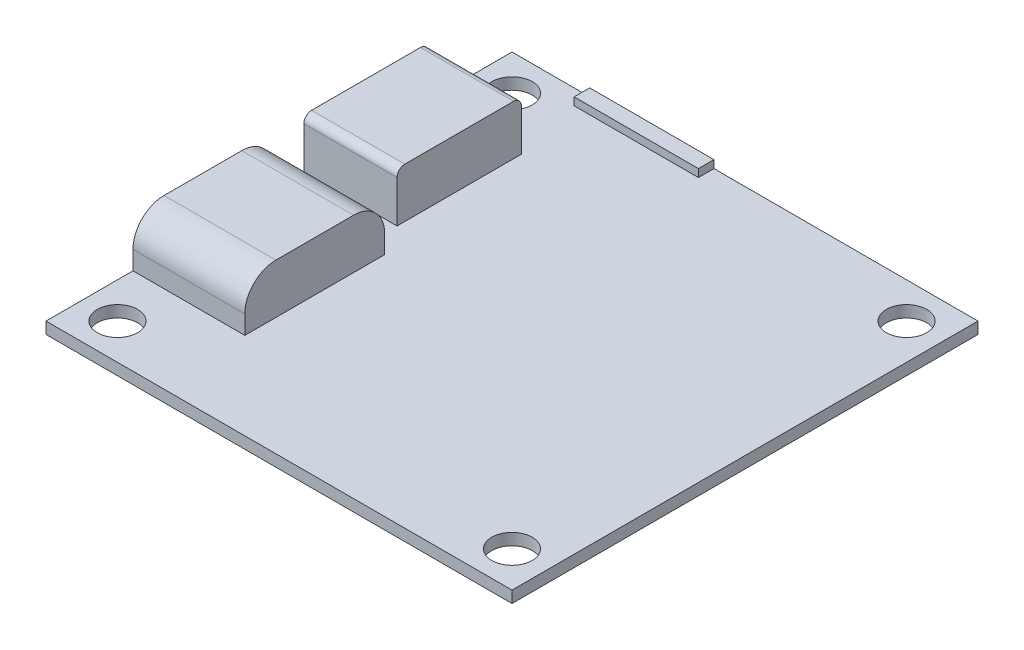
from build123d import *

# Parameters (mm, degrees)
SKETCH1_W               = 30
SKETCH1_H               = 30
BOSS_EXTRUDE1_DEPTH     = 0.375
SKETCH2_R               = 1.3
CUT_EXTRUDE1_DEPTH      = 1.75
MIRROR2_COPY_1_SKETCH_R = 1.3
MIRROR2_COPY_1_DEPTH    = 1.75
SKETCH3_W               = 7.2
SKETCH3_H               = 9
SKETCH3_W_2             = 6
SKETCH3_H_2             = 8
BOSS_EXTRUDE2_DEPTH     = 3.2
FILLET1_R               = 2
FILLET2_R               = 0.5
SKETCH4_W               = 8
SKETCH4_H               = 1
BOSS_EXTRUDE3_DEPTH     = 0.5


with BuildPart() as part:
    # Sketch1 → Boss-Extrude1 (new body, symmetric)
    with BuildSketch(Plane(origin=(0, 0, 0), x_dir=(1, 0, 0), z_dir=(0, 1, 0))):
        Rectangle(SKETCH1_W, SKETCH1_H)
    extrude(amount=BOSS_EXTRUDE1_DEPTH, both=True)

    # Sketch2 → Cut-Extrude1 (cut, through all)
    with BuildSketch(Plane(origin=(0, 0.375, 0), x_dir=(1, 0, 0), z_dir=(0, 1, 0))):
        with Locations((-12.7, 12.7)):
            Circle(SKETCH2_R)
    cut_extrude1 = extrude(amount=-CUT_EXTRUDE1_DEPTH, mode=Mode.SUBTRACT)

    # Mirror1: Cut-Extrude1 across plane
    add(cut_extrude1.mirror(Plane(origin=(0, 0, 0), x_dir=(0, 0, 1), z_dir=(1, 0, 0))), mode=Mode.SUBTRACT)

    # Mirror2: Cut-Extrude1 across plane
    add(cut_extrude1.mirror(Plane.XY), mode=Mode.SUBTRACT)

    # Mirror2 copy 1 sketch → Mirror2 copy 1 (cut, through all)
    with BuildSketch(Plane(origin=(0, 0.375, 0), x_dir=(-1, 0, 0), z_dir=(0, 1, 0))):
        with Locations((-12.7, 12.7)):
            Circle(MIRROR2_COPY_1_SKETCH_R)
    extrude(amount=-MIRROR2_COPY_1_DEPTH, mode=Mode.SUBTRACT)

    # Sketch3 → Boss-Extrude2 (add)
    with BuildSketch(Plane(origin=(0, 0.375, 0), x_dir=(1, 0, 0), z_dir=(0, 1, 0))):
        with Locations((-11.4, -4.9)):
            Rectangle(SKETCH3_W, SKETCH3_H)
        with Locations((-12, 5.6)):
            Rectangle(SKETCH3_W_2, SKETCH3_H_2)
    extrude(amount=BOSS_EXTRUDE2_DEPTH)

    # Fillet1
    fillet1_edges = [part.edges().sort_by_distance(p)[0] for p in [
        (-11.4, 3.575, 9.4),
        (-11.4, 3.575, 0.4),
    ]]
    fillet(fillet1_edges, radius=FILLET1_R)

    # Fillet2
    fillet2_edges = [part.edges().sort_by_distance(p)[0] for p in [
        (-12, 3.575, -1.6),
        (-12, 3.575, -9.6),
    ]]
    fillet(fillet2_edges, radius=FILLET2_R)

    # Sketch4 → Boss-Extrude3 (add, symmetric)
    with BuildSketch(Plane(origin=(0, 0.375, 0), x_dir=(1, 0, 0), z_dir=(0, 1, 0))):
        with Locations((-6, 14.5)):
            Rectangle(SKETCH4_W, SKETCH4_H)
    extrude(amount=BOSS_EXTRUDE3_DEPTH, both=True)


solid = part.part
